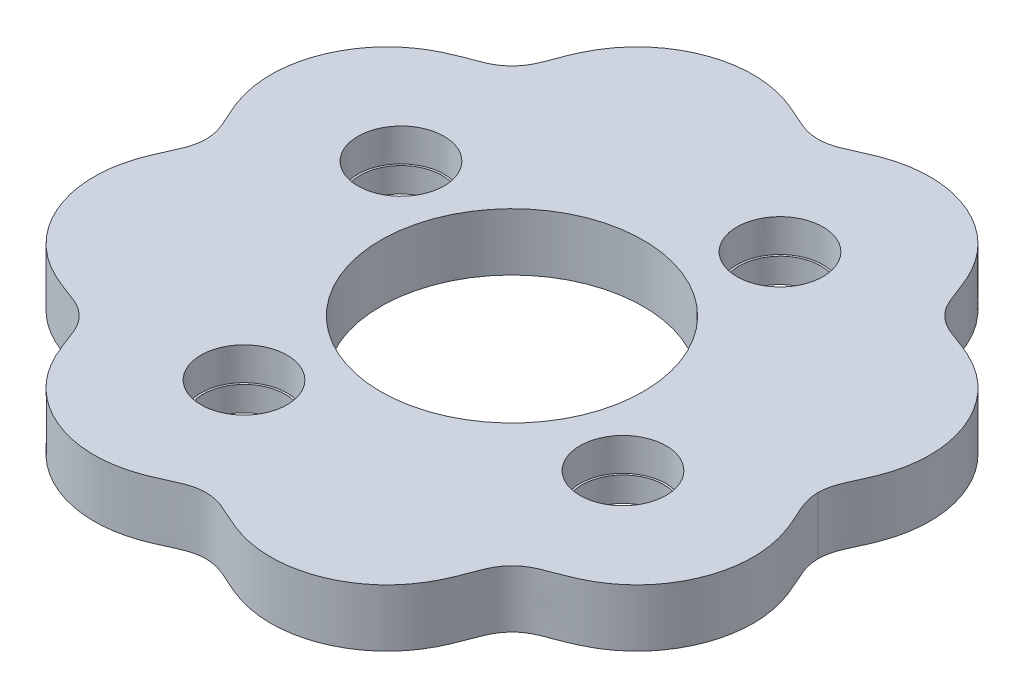
from build123d import *

# Parameters (mm, degrees)
BOSS_EXTRUDE1_DEPTH = 7
SKETCH3_R           = 16
SKETCH3_R_2         = 5.25
CUT_EXTRUDE1_DEPTH  = 7
CUT_EXTRUDE2_DEPTH  = 7
SKETCH5_R           = 5.25
SKETCH5_R_2         = 5
BOSS_EXTRUDE2_DEPTH = 3


with BuildPart() as part:
    # Sketch2 → Boss-Extrude1 (new body)
    with BuildSketch(Plane(origin=(0, 0, 0), x_dir=(1, 0, 0), z_dir=(0, 1, 0))):
        with BuildLine():
            add(Edge.make_bspline(
                [(37.500000178, 0), (37.500001348, -0.153650042), (37.516723117, -0.585734713), (37.60134551, -1.155885936), (37.799451038, -1.845132779), (38.055257689, -2.50061582), (38.284413658, -3.01884437), (38.547573645, -3.586057627), (38.834335204, -4.207231283), (39.213023964, -5.071386775), (39.642902809, -6.195484546), (40.034770345, -7.545626157), (40.309114863, -9.129071904), (40.402480997, -10.733442687), (40.292330227, -12.739242447), (39.800709206, -15.115411572), (38.875008006, -17.372282299), (37.550500891, -19.416826213), (36.201869244, -20.937061223), (34.991297456, -22.022332107), (33.664442598, -22.961820777), (32.418877976, -23.648429526), (31.307176029, -24.144813461), (30.415442254, -24.492540623), (29.760772524, -24.733252947), (29.159260868, -24.953726937), (28.615153012, -25.166050116), (27.968227921, -25.455751973), (27.242450172, -25.869161743), (26.486758972, -26.478530797), (25.788934233, -27.338578085), (25.333439826, -28.199550113), (25.02084924, -28.978917238), (24.756184284, -29.69717513), (24.520071708, -30.342148991), (24.176798097, -31.229963234), (23.685673389, -32.343953643), (23.006023391, -33.593318677), (22.074382722, -34.925670234), (20.99628636, -36.142619362), (19.483992231, -37.500137581), (17.436434568, -38.843473511), (15.165772212, -39.787003781), (12.765640508, -40.290729235), (10.727941267, -40.403684264), (9.098120231, -40.306732746), (7.490297544, -40.023060283), (6.12050869, -39.618509318), (4.980859334, -39.175936442), (3.981084292, -38.733166074), (3.107747272, -38.323212218), (2.16284156, -37.896233325), (1.102684883, -37.568652762), (-4e-09, -37.451718585), (-1.102684874, -37.568652759), (-2.162841573, -37.896233332), (-3.107747248, -38.323212203), (-3.981084328, -38.733166098), (-4.980859269, -39.175936398), (-6.120508811, -39.6185094), (-7.490297349, -40.023060149), (-9.098120503, -40.306732933), (-10.727940878, -40.403683996), (-12.765641194, -40.290729708), (-15.165770912, -39.787002885), (-17.436436591, -38.843474905), (-19.48398961, -37.500135775), (-20.996290415, -36.142622155), (-22.074374394, -34.925664496), (-23.006039129, -33.59332952), (-23.685647307, -32.343935674), (-24.176838549, -31.229991103), (-24.570729586, -30.210893235), (-24.899588849, -29.300399238), (-25.267416458, -28.324512461), (-25.788900803, -27.338555053), (-26.486780724, -26.478545782), (-27.242436428, -25.869152274), (-27.968236735, -25.455758045), (-28.615147496, -25.166046316), (-29.159264206, -24.953729236), (-29.760770668, -24.733251668), (-30.415443148, -24.492541238), (-31.307175489, -24.144813089), (-32.41887831, -23.648429756), (-33.6644424, -22.96182064), (-34.99129756, -22.022332179), (-36.201869193, -20.937061188), (-37.550500924, -19.416826235), (-38.875007981, -17.372282282), (-39.800709222, -15.115411584), (-40.292330218, -12.739242441), (-40.402481002, -10.733442691), (-40.309114859, -9.129071901), (-40.034770347, -7.545626159), (-39.642902807, -6.195484545), (-39.213023965, -5.071386776), (-38.834335204, -4.207231283), (-38.547573646, -3.586057627), (-38.284413658, -3.01884437), (-38.055257689, -2.50061582), (-37.799451038, -1.845132779), (-37.60134551, -1.155885936), (-37.516723117, -0.585734713), (-37.500001348, -0.153650042), (-37.500000178, 0)],
                knots=[0.119900748, 0.119900748, 0.119900748, 0.119900748, 0.119900748, 0.123359436, 0.129627259, 0.132815238, 0.136003217, 0.139191195, 0.142379174, 0.14689104, 0.151402906, 0.160426638, 0.169450869, 0.1784751, 0.187499512, 0.196523925, 0.214572937, 0.232831382, 0.241960244, 0.251089107, 0.260218415, 0.269347723, 0.278476117, 0.283040314, 0.287604511, 0.290890352, 0.294176194, 0.297462035, 0.300747877, 0.306837966, 0.312927068, 0.319161334, 0.325493528, 0.328659626, 0.331825723, 0.336390118, 0.340954513, 0.350083302, 0.35921236, 0.368341418, 0.377470301, 0.386599184, 0.404857643, 0.423193135, 0.432360527, 0.441527919, 0.450695565, 0.459863212, 0.469030281, 0.473613816, 0.47819735, 0.484472892, 0.490748434, 0.496943117, 0.503056883, 0.509251566, 0.515527108, 0.52180265, 0.526386184, 0.530969719, 0.540136788, 0.549304435, 0.558472081, 0.567639473, 0.576806865, 0.595142357, 0.613400816, 0.622529699, 0.631658582, 0.64078764, 0.649916698, 0.659045487, 0.663609882, 0.668174277, 0.674506472, 0.680838666, 0.687072932, 0.693162034, 0.699252123, 0.702537965, 0.705823806, 0.709109648, 0.712395489, 0.716959686, 0.721523883, 0.730652277, 0.739781585, 0.748910893, 0.758039756, 0.767168618, 0.785427063, 0.803476075, 0.812500488, 0.8215249, 0.830549131, 0.839573362, 0.848597094, 0.85310896, 0.857620826, 0.860808805, 0.863996783, 0.867184762, 0.870372741, 0.876640564, 0.880099252, 0.880099252, 0.880099252, 0.880099252, 0.880099252], degree=4))
            add(Edge.make_bspline(
                [(37.500000178, 0), (37.500001348, 0.153650042), (37.516723117, 0.585734713), (37.60134551, 1.155885936), (37.799451038, 1.845132779), (38.055257689, 2.50061582), (38.284413658, 3.018844371), (38.547573645, 3.586057627), (38.834335204, 4.207231284), (39.213023964, 5.071386775), (39.642902809, 6.195484546), (40.034770345, 7.545626157), (40.309114863, 9.129071904), (40.402480997, 10.733442688), (40.292330227, 12.739242447), (39.800709205, 15.115411572), (38.875008006, 17.3722823), (37.550500891, 19.416826213), (36.201869244, 20.937061223), (34.991297456, 22.022332107), (33.664442598, 22.961820777), (32.418877976, 23.648429526), (31.307176029, 24.144813461), (30.415442254, 24.492540623), (29.760772524, 24.733252947), (29.159260868, 24.953726937), (28.615153012, 25.166050117), (27.968227921, 25.455751974), (27.242450172, 25.869161744), (26.486758972, 26.478530797), (25.788934233, 27.338578085), (25.333439826, 28.199550113), (25.02084924, 28.978917238), (24.756184284, 29.69717513), (24.520071708, 30.342148991), (24.176798097, 31.229963234), (23.685673389, 32.343953643), (23.006023391, 33.593318677), (22.074382722, 34.925670234), (20.99628636, 36.142619362), (19.483992231, 37.500137582), (17.436434568, 38.843473511), (15.165772212, 39.787003781), (12.765640508, 40.290729235), (10.727941267, 40.403684265), (9.098120231, 40.306732746), (7.490297544, 40.023060283), (6.12050869, 39.618509318), (4.980859334, 39.175936443), (3.981084292, 38.733166074), (3.107747271, 38.323212218), (2.162841559, 37.896233325), (1.102684882, 37.568652762), (-4e-09, 37.451718586), (-1.102684874, 37.568652759), (-2.162841573, 37.896233332), (-3.107747248, 38.323212203), (-3.981084328, 38.733166098), (-4.980859269, 39.175936399), (-6.120508811, 39.6185094), (-7.490297349, 40.023060149), (-9.098120503, 40.306732933), (-10.727940878, 40.403683996), (-12.765641194, 40.290729708), (-15.165770912, 39.787002885), (-17.436436591, 38.843474905), (-19.48398961, 37.500135776), (-20.996290415, 36.142622155), (-22.074374394, 34.925664496), (-23.006039129, 33.59332952), (-23.685647307, 32.343935674), (-24.176838549, 31.229991103), (-24.570729586, 30.210893235), (-24.899588849, 29.300399238), (-25.267416458, 28.324512461), (-25.788900803, 27.338555053), (-26.486780724, 26.478545782), (-27.242436428, 25.869152274), (-27.968236735, 25.455758045), (-28.615147496, 25.166046316), (-29.159264206, 24.953729236), (-29.760770668, 24.733251668), (-30.415443148, 24.492541238), (-31.307175489, 24.144813089), (-32.418878311, 23.648429756), (-33.6644424, 22.96182064), (-34.99129756, 22.022332179), (-36.201869193, 20.937061188), (-37.550500924, 19.416826235), (-38.875007981, 17.372282282), (-39.800709222, 15.115411584), (-40.292330218, 12.739242441), (-40.402481002, 10.733442691), (-40.309114859, 9.129071901), (-40.034770347, 7.545626159), (-39.642902807, 6.195484545), (-39.213023965, 5.071386776), (-38.834335204, 4.207231283), (-38.547573646, 3.586057627), (-38.284413658, 3.01884437), (-38.055257689, 2.50061582), (-37.799451038, 1.845132779), (-37.60134551, 1.155885936), (-37.516723117, 0.585734713), (-37.500001348, 0.153650042), (-37.500000178, 0)],
                knots=[0.119900748, 0.119900748, 0.119900748, 0.119900748, 0.119900748, 0.123359436, 0.129627259, 0.132815238, 0.136003217, 0.139191195, 0.142379174, 0.14689104, 0.151402906, 0.160426638, 0.169450869, 0.1784751, 0.187499512, 0.196523925, 0.214572937, 0.232831382, 0.241960244, 0.251089107, 0.260218415, 0.269347723, 0.278476117, 0.283040314, 0.287604511, 0.290890352, 0.294176194, 0.297462035, 0.300747877, 0.306837966, 0.312927068, 0.319161334, 0.325493528, 0.328659626, 0.331825723, 0.336390118, 0.340954513, 0.350083302, 0.35921236, 0.368341418, 0.377470301, 0.386599184, 0.404857643, 0.423193135, 0.432360527, 0.441527919, 0.450695565, 0.459863212, 0.469030281, 0.473613816, 0.47819735, 0.484472892, 0.490748434, 0.496943117, 0.503056883, 0.509251566, 0.515527108, 0.52180265, 0.526386184, 0.530969719, 0.540136788, 0.549304435, 0.558472081, 0.567639473, 0.576806865, 0.595142357, 0.613400816, 0.622529699, 0.631658582, 0.64078764, 0.649916698, 0.659045487, 0.663609882, 0.668174277, 0.674506472, 0.680838666, 0.687072932, 0.693162034, 0.699252123, 0.702537965, 0.705823806, 0.709109648, 0.712395489, 0.716959686, 0.721523883, 0.730652277, 0.739781585, 0.748910893, 0.758039756, 0.767168618, 0.785427063, 0.803476075, 0.812500488, 0.8215249, 0.830549131, 0.839573362, 0.848597094, 0.85310896, 0.857620826, 0.860808805, 0.863996783, 0.867184762, 0.870372741, 0.876640564, 0.880099252, 0.880099252, 0.880099252, 0.880099252, 0.880099252], degree=4))
        make_face()
    extrude(amount=BOSS_EXTRUDE1_DEPTH)

    # Sketch3 → Cut-Extrude1 (cut)
    with BuildSketch(Plane(origin=(0, 7, 0), x_dir=(1, 0, 0), z_dir=(0, 1, 0))):
        with Locations(Location((0, 0, 0), (0, 0, 270))):
            Circle(SKETCH3_R)
        with Locations(Location((23.096990508, -9.567080508, 0), (0, 0, 270))):
            Circle(SKETCH3_R_2)
        with Locations(Location((-9.567080508, -23.096990508, 0), (0, 0, 270))):
            Circle(SKETCH3_R_2)
        with Locations(Location((-23.096990508, 9.567080508, 0), (0, 0, 270))):
            Circle(SKETCH3_R_2)
        with Locations(Location((9.567080508, 23.096990508, 0), (0, 0, 270))):
            Circle(SKETCH3_R_2)
    extrude(amount=-CUT_EXTRUDE1_DEPTH, mode=Mode.SUBTRACT)

    # Sketch4 → Cut-Extrude2 (cut)
    with BuildSketch(Plane.XZ):
        with BuildLine():
            add(Edge.make_bspline(
                [(37.500000178, 0), (37.500001348, 0.153650042), (37.516723117, 0.585734713), (37.60134551, 1.155885936), (37.799451038, 1.845132779), (38.055257689, 2.50061582), (38.284413658, 3.01884437), (38.547573645, 3.586057627), (38.834335204, 4.207231283), (39.213023964, 5.071386775), (39.642902809, 6.195484546), (40.034770345, 7.545626157), (40.309114863, 9.129071904), (40.402480997, 10.733442687), (40.292330227, 12.739242447), (39.800709206, 15.115411572), (38.875008006, 17.372282299), (37.550500891, 19.416826213), (36.201869244, 20.937061223), (34.991297456, 22.022332107), (33.664442598, 22.961820777), (32.418877976, 23.648429526), (31.307176029, 24.144813461), (30.415442254, 24.492540623), (29.760772524, 24.733252947), (29.159260868, 24.953726937), (28.615153012, 25.166050116), (27.968227921, 25.455751973), (27.242450172, 25.869161743), (26.486758972, 26.478530797), (25.788934233, 27.338578085), (25.333439826, 28.199550113), (25.02084924, 28.978917238), (24.756184284, 29.69717513), (24.520071708, 30.342148991), (24.176798097, 31.229963234), (23.685673389, 32.343953643), (23.006023391, 33.593318677), (22.074382722, 34.925670234), (20.99628636, 36.142619362), (19.483992231, 37.500137581), (17.436434568, 38.843473511), (15.165772212, 39.787003781), (12.765640508, 40.290729235), (10.727941267, 40.403684264), (9.098120231, 40.306732746), (7.490297544, 40.023060283), (6.12050869, 39.618509318), (4.980859334, 39.175936442), (3.981084292, 38.733166074), (3.107747272, 38.323212218), (2.16284156, 37.896233325), (1.102684883, 37.568652762), (-4e-09, 37.451718585), (-1.102684874, 37.568652759), (-2.162841573, 37.896233332), (-3.107747248, 38.323212203), (-3.981084328, 38.733166098), (-4.980859269, 39.175936398), (-6.120508811, 39.6185094), (-7.490297349, 40.023060149), (-9.098120503, 40.306732933), (-10.727940878, 40.403683996), (-12.765641194, 40.290729708), (-15.165770912, 39.787002885), (-17.436436591, 38.843474905), (-19.48398961, 37.500135775), (-20.996290415, 36.142622155), (-22.074374394, 34.925664496), (-23.006039129, 33.59332952), (-23.685647307, 32.343935674), (-24.176838549, 31.229991103), (-24.570729586, 30.210893235), (-24.899588849, 29.300399238), (-25.267416458, 28.324512461), (-25.788900803, 27.338555053), (-26.486780724, 26.478545782), (-27.242436428, 25.869152274), (-27.968236735, 25.455758045), (-28.615147496, 25.166046316), (-29.159264206, 24.953729236), (-29.760770668, 24.733251668), (-30.415443148, 24.492541238), (-31.307175489, 24.144813089), (-32.41887831, 23.648429756), (-33.6644424, 22.96182064), (-34.99129756, 22.022332179), (-36.201869193, 20.937061188), (-37.550500924, 19.416826235), (-38.875007981, 17.372282282), (-39.800709222, 15.115411584), (-40.292330218, 12.739242441), (-40.402481002, 10.733442691), (-40.309114859, 9.129071901), (-40.034770347, 7.545626159), (-39.642902807, 6.195484545), (-39.213023965, 5.071386776), (-38.834335204, 4.207231283), (-38.547573646, 3.586057627), (-38.284413658, 3.01884437), (-38.055257689, 2.50061582), (-37.799451038, 1.845132779), (-37.60134551, 1.155885936), (-37.516723117, 0.585734713), (-37.500001348, 0.153650042), (-37.500000178, 0)],
                knots=[0.119900748, 0.119900748, 0.119900748, 0.119900748, 0.119900748, 0.123359436, 0.129627259, 0.132815238, 0.136003217, 0.139191195, 0.142379174, 0.14689104, 0.151402906, 0.160426638, 0.169450869, 0.1784751, 0.187499512, 0.196523925, 0.214572937, 0.232831382, 0.241960244, 0.251089107, 0.260218415, 0.269347723, 0.278476117, 0.283040314, 0.287604511, 0.290890352, 0.294176194, 0.297462035, 0.300747877, 0.306837966, 0.312927068, 0.319161334, 0.325493528, 0.328659626, 0.331825723, 0.336390118, 0.340954513, 0.350083302, 0.35921236, 0.368341418, 0.377470301, 0.386599184, 0.404857643, 0.423193135, 0.432360527, 0.441527919, 0.450695565, 0.459863212, 0.469030281, 0.473613816, 0.47819735, 0.484472892, 0.490748434, 0.496943117, 0.503056883, 0.509251566, 0.515527108, 0.52180265, 0.526386184, 0.530969719, 0.540136788, 0.549304435, 0.558472081, 0.567639473, 0.576806865, 0.595142357, 0.613400816, 0.622529699, 0.631658582, 0.64078764, 0.649916698, 0.659045487, 0.663609882, 0.668174277, 0.674506472, 0.680838666, 0.687072932, 0.693162034, 0.699252123, 0.702537965, 0.705823806, 0.709109648, 0.712395489, 0.716959686, 0.721523883, 0.730652277, 0.739781585, 0.748910893, 0.758039756, 0.767168618, 0.785427063, 0.803476075, 0.812500488, 0.8215249, 0.830549131, 0.839573362, 0.848597094, 0.85310896, 0.857620826, 0.860808805, 0.863996783, 0.867184762, 0.870372741, 0.876640564, 0.880099252, 0.880099252, 0.880099252, 0.880099252, 0.880099252], degree=4))
            add(Edge.make_bspline(
                [(-37.500000178, 0), (-37.500001348, -0.153650042), (-37.516723117, -0.585734713), (-37.60134551, -1.155885936), (-37.799451038, -1.845132779), (-38.055257689, -2.50061582), (-38.284413658, -3.01884437), (-38.547573646, -3.586057627), (-38.834335204, -4.207231283), (-39.213023965, -5.071386776), (-39.642902807, -6.195484545), (-40.034770347, -7.545626159), (-40.309114859, -9.129071901), (-40.402481002, -10.733442691), (-40.292330218, -12.739242441), (-39.800709222, -15.115411584), (-38.875007981, -17.372282282), (-37.550500924, -19.416826235), (-36.201869193, -20.937061188), (-34.99129756, -22.022332179), (-33.6644424, -22.96182064), (-32.418878311, -23.648429756), (-31.307175489, -24.144813089), (-30.415443148, -24.492541238), (-29.760770668, -24.733251668), (-29.159264206, -24.953729236), (-28.615147496, -25.166046316), (-27.968236735, -25.455758045), (-27.242436428, -25.869152274), (-26.486780724, -26.478545782), (-25.788900803, -27.338555053), (-25.267416458, -28.324512461), (-24.899588849, -29.300399238), (-24.570729586, -30.210893235), (-24.176838549, -31.229991103), (-23.685647307, -32.343935674), (-23.006039129, -33.59332952), (-22.074374394, -34.925664496), (-20.996290415, -36.142622155), (-19.48398961, -37.500135776), (-17.436436591, -38.843474905), (-15.165770912, -39.787002885), (-12.765641194, -40.290729708), (-10.727940878, -40.403683996), (-9.098120503, -40.306732933), (-7.490297349, -40.023060149), (-6.120508811, -39.6185094), (-4.980859269, -39.175936399), (-3.981084328, -38.733166098), (-3.107747248, -38.323212203), (-2.162841573, -37.896233332), (-1.102684874, -37.568652759), (-4e-09, -37.451718586), (1.102684882, -37.568652762), (2.162841559, -37.896233325), (3.107747271, -38.323212218), (3.981084292, -38.733166074), (4.980859334, -39.175936443), (6.12050869, -39.618509318), (7.490297544, -40.023060283), (9.098120231, -40.306732746), (10.727941267, -40.403684265), (12.765640508, -40.290729235), (15.165772212, -39.787003781), (17.436434568, -38.843473511), (19.483992231, -37.500137582), (20.99628636, -36.142619362), (22.074382722, -34.925670234), (23.006023391, -33.593318677), (23.685673389, -32.343953643), (24.176798097, -31.229963234), (24.520071708, -30.342148991), (24.756184284, -29.69717513), (25.02084924, -28.978917238), (25.333439826, -28.199550113), (25.788934233, -27.338578085), (26.486758972, -26.478530797), (27.242450172, -25.869161744), (27.968227921, -25.455751974), (28.615153012, -25.166050117), (29.159260868, -24.953726937), (29.760772524, -24.733252947), (30.415442254, -24.492540623), (31.307176029, -24.144813461), (32.418877976, -23.648429526), (33.664442598, -22.961820777), (34.991297456, -22.022332107), (36.201869244, -20.937061223), (37.550500891, -19.416826213), (38.875008006, -17.3722823), (39.800709205, -15.115411572), (40.292330227, -12.739242447), (40.402480997, -10.733442688), (40.309114863, -9.129071904), (40.034770345, -7.545626157), (39.642902809, -6.195484546), (39.213023964, -5.071386775), (38.834335204, -4.207231284), (38.547573645, -3.586057627), (38.284413658, -3.018844371), (38.055257689, -2.50061582), (37.799451038, -1.845132779), (37.60134551, -1.155885936), (37.516723117, -0.585734713), (37.500001348, -0.153650042), (37.500000178, 0)],
                knots=[0.119900748, 0.119900748, 0.119900748, 0.119900748, 0.119900748, 0.123359436, 0.129627259, 0.132815238, 0.136003217, 0.139191195, 0.142379174, 0.14689104, 0.151402906, 0.160426638, 0.169450869, 0.1784751, 0.187499512, 0.196523925, 0.214572937, 0.232831382, 0.241960244, 0.251089107, 0.260218415, 0.269347723, 0.278476117, 0.283040314, 0.287604511, 0.290890352, 0.294176194, 0.297462035, 0.300747877, 0.306837966, 0.312927068, 0.319161334, 0.325493528, 0.331825723, 0.336390118, 0.340954513, 0.350083302, 0.35921236, 0.368341418, 0.377470301, 0.386599184, 0.404857643, 0.423193135, 0.432360527, 0.441527919, 0.450695565, 0.459863212, 0.469030281, 0.473613816, 0.47819735, 0.484472892, 0.490748434, 0.496943117, 0.503056883, 0.509251566, 0.515527108, 0.52180265, 0.526386184, 0.530969719, 0.540136788, 0.549304435, 0.558472081, 0.567639473, 0.576806865, 0.595142357, 0.613400816, 0.622529699, 0.631658582, 0.64078764, 0.649916698, 0.659045487, 0.663609882, 0.668174277, 0.671340374, 0.674506472, 0.680838666, 0.687072932, 0.693162034, 0.699252123, 0.702537965, 0.705823806, 0.709109648, 0.712395489, 0.716959686, 0.721523883, 0.730652277, 0.739781585, 0.748910893, 0.758039756, 0.767168618, 0.785427063, 0.803476075, 0.812500488, 0.8215249, 0.830549131, 0.839573362, 0.848597094, 0.85310896, 0.857620826, 0.860808805, 0.863996783, 0.867184762, 0.870372741, 0.876640564, 0.880099252, 0.880099252, 0.880099252, 0.880099252, 0.880099252], degree=4))
        make_face()
        with BuildLine():
            add(Edge.make_bspline(
                [(-37.300000178, -1.524e-06), (-37.300005335, -0.676867371), (-37.427636497, -1.325473476), (-37.853250651, -2.584965326), (-38.147131523, -3.195245044), (-38.710737195, -4.418667543), (-38.982798601, -5.033561115), (-39.450771862, -6.288224734), (-39.648035819, -6.927553077), (-39.875673706, -7.908844077), (-39.940344955, -8.239602513), (-40.046090854, -8.908827903), (-40.087286369, -9.248679407), (-40.172949866, -10.27022305), (-40.179625206, -10.947626333), (-40.096430658, -12.295492001), (-40.006581856, -12.965955902), (-39.798317767, -13.966368295), (-39.716248424, -14.299914705), (-39.529875703, -14.955124894), (-39.425421525, -15.277863119), (-39.07900274, -16.231799922), (-38.804163449, -16.848799053), (-38.166153555, -18.044644678), (-37.799492988, -18.627625556), (-36.995130035, -19.722329216), (-36.55702023, -20.236493497), (-35.609382413, -21.198851965), (-35.098848237, -21.647731332), (-34.006848553, -22.473314445), (-33.436641819, -22.841333302), (-32.252551038, -23.49658613), (-31.638105387, -23.782781365), (-30.693579545, -24.169797582), (-30.374923098, -24.29196642), (-29.735334328, -24.530156066), (-29.414121244, -24.64587707), (-28.776119551, -24.887840957), (-28.459558035, -25.014623888), (-27.841899581, -25.30496618), (-27.538474652, -25.470402701), (-26.968530323, -25.84818003), (-26.70266287, -26.059307537), (-26.212204012, -26.529609939), (-25.985689891, -26.791762949), (-25.586463853, -27.347680771), (-25.41329678, -27.640928729), (-25.106118272, -28.250061479), (-24.972145407, -28.566214123), (-24.721951409, -29.207052359), (-24.604673392, -29.531396076), (-24.365978823, -30.178006246), (-24.244860769, -30.500422525), (-23.861965565, -31.457863081), (-23.579994139, -32.082751199), (-22.93073246, -33.289703159), (-22.564564445, -33.872330289), (-21.944749407, -34.710853127), (-21.725410999, -34.985571353), (-21.270313026, -35.513530833), (-21.034058454, -35.767647044), (-20.299828428, -36.501142055), (-19.77651621, -36.951814008), (-18.662658422, -37.776981752), (-18.067184766, -38.153631121), (-16.84205779, -38.808251323), (-16.210381542, -39.088693428), (-15.234619198, -39.440087375), (-14.904636476, -39.545623277), (-14.235030876, -39.733055651), (-13.893995034, -39.815213549), (-12.183094407, -40.161008791), (-10.804309777, -40.234150035), (-9.068024089, -40.066663686), (-8.719971551, -40.019815553), (-8.033988167, -39.901414802), (-7.694604804, -39.829735338), (-6.686761662, -39.579051281), (-6.02890771, -39.363367369), (-4.734913886, -38.856903314), (-4.09967909, -38.563862442), (-2.831226885, -37.978648162), (-2.195461735, -37.68983752), (-1.177345947, -37.415650241), (-0.830881373, -37.351821484), (-0.138817065, -37.29091559), (0.20907518, -37.292911809), (0.908697102, -37.363847996), (1.254123511, -37.432795894), (1.923534855, -37.620991628), (2.250175655, -37.740536869), (2.894567623, -38.007677129), (3.212569296, -38.154445485), (3.848679122, -38.448235746), (4.166662192, -38.595380732), (5.126011798, -39.018034516), (5.77299927, -39.273995175), (7.093462946, -39.693795626), (7.766556663, -39.858965602), (8.79794485, -40.031088074), (9.145338463, -40.075950894), (9.84763557, -40.139559133), (10.204439892, -40.158296893), (11.981061205, -40.183352107), (13.374101934, -39.99116426), (15.0807472, -39.4906324), (15.418995639, -39.377488677), (16.081101817, -39.128399482), (16.406210156, -38.992100462), (17.363980082, -38.548492104), (17.97919541, -38.206686663), (18.866236672, -37.623228073), (19.157096225, -37.415961043), (19.7199732, -36.981810571), (19.991631279, -36.755377595), (20.777834873, -36.048551371), (21.26373655, -35.540752153), (21.934837883, -34.723797907), (22.148877277, -34.442236285), (22.557321054, -33.860326574), (22.751308058, -33.560329192), (23.296633068, -32.645197526), (23.613079431, -32.01037547), (24.035024821, -31.030456758), (24.167085908, -30.699362692), (24.42071489, -30.03357086), (24.542165455, -29.698502186), (24.789943229, -29.030340214), (24.916288451, -28.697254212), (25.203031469, -28.04487583), (25.365328746, -27.723501519), (25.738863592, -27.118626541), (25.949588891, -26.83484909), (26.425345949, -26.30959178), (26.693427061, -26.066305249), (27.262376931, -25.640526196), (27.56458752, -25.45587752), (28.196201984, -25.129880607), (28.525768024, -24.988616885), (29.195057198, -24.725991917), (29.534624796, -24.603555748), (30.211020774, -24.35374453), (30.54805671, -24.22674371), (31.547163494, -23.824103094), (32.196759504, -23.525970845), (33.44512828, -22.83807073), (34.04463883, -22.449633109), (34.902881218, -21.793010366), (35.18215621, -21.561865079), (35.726440643, -21.073853349), (35.992909512, -20.815365155), (36.754934237, -20.015059637), (37.215569576, -19.447621742), (38.045919188, -18.247692555), (38.41581225, -17.614905719), (39.060809726, -16.283216984), (39.327825486, -15.601135481), (39.755290796, -14.205785793), (39.915743077, -13.492518407), (40.073287437, -12.398288082), (40.111713427, -12.029358579), (40.159120983, -11.296377239), (40.168380307, -10.930685523), (40.153413888, -9.835974665), (40.086539323, -9.109314524), (39.899940664, -8.024097027), (39.822944519, -7.661850311), (39.641972096, -6.946076066), (39.53821078, -6.592991809), (39.19106012, -5.546715434), (38.9097543, -4.867241305), (38.454863731, -3.859944684), (38.297872988, -3.526119045), (37.992404669, -2.855385887), (37.844569648, -2.518245277), (37.590630842, -1.828852716), (37.484865024, -1.476478384), (37.339064604, -0.747927725), (37.300003029, -0.374141758), (37.300000178, -1.524e-06)],
                knots=[0, 0, 0, 0, 0.015625, 0.015625, 0.03125, 0.03125, 0.046875, 0.046875, 0.0625, 0.0625, 0.0703125, 0.0703125, 0.078125, 0.078125, 0.09375, 0.09375, 0.109375, 0.109375, 0.1171875, 0.1171875, 0.125, 0.125, 0.140625, 0.140625, 0.15625, 0.15625, 0.171875, 0.171875, 0.1875, 0.1875, 0.203125, 0.203125, 0.21875, 0.21875, 0.2265625, 0.2265625, 0.234375, 0.234375, 0.2421875, 0.2421875, 0.25, 0.25, 0.2578125, 0.2578125, 0.265625, 0.265625, 0.2734375, 0.2734375, 0.28125, 0.28125, 0.2890625, 0.2890625, 0.296875, 0.296875, 0.3125, 0.3125, 0.328125, 0.328125, 0.3359375, 0.3359375, 0.34375, 0.34375, 0.359375, 0.359375, 0.375, 0.375, 0.390625, 0.390625, 0.3984375, 0.3984375, 0.40625, 0.40625, 0.4375, 0.4375, 0.4453125, 0.4453125, 0.453125, 0.453125, 0.46875, 0.46875, 0.484375, 0.484375, 0.5, 0.5, 0.5078125, 0.5078125, 0.515625, 0.515625, 0.5234375, 0.5234375, 0.53125, 0.53125, 0.5390625, 0.5390625, 0.546875, 0.546875, 0.5625, 0.5625, 0.578125, 0.578125, 0.5859375, 0.5859375, 0.59375, 0.59375, 0.625, 0.625, 0.6328125, 0.6328125, 0.640625, 0.640625, 0.65625, 0.65625, 0.6640625, 0.6640625, 0.671875, 0.671875, 0.6875, 0.6875, 0.6953125, 0.6953125, 0.703125, 0.703125, 0.71875, 0.71875, 0.7265625, 0.7265625, 0.734375, 0.734375, 0.7421875, 0.7421875, 0.75, 0.75, 0.7578125, 0.7578125, 0.765625, 0.765625, 0.7734375, 0.7734375, 0.78125, 0.78125, 0.7890625, 0.7890625, 0.796875, 0.796875, 0.8125, 0.8125, 0.828125, 0.828125, 0.8359375, 0.8359375, 0.84375, 0.84375, 0.859375, 0.859375, 0.875, 0.875, 0.890625, 0.890625, 0.90625, 0.90625, 0.9140625, 0.9140625, 0.921875, 0.921875, 0.9375, 0.9375, 0.9453125, 0.9453125, 0.953125, 0.953125, 0.96875, 0.96875, 0.9765625, 0.9765625, 0.984375, 0.984375, 0.9921875, 0.9921875, 1, 1, 1, 1], degree=3))
            add(Edge.make_bspline(
                [(37.300000178, -1.524e-06), (37.300005208, 0.660144226), (37.421411779, 1.295517379), (37.831734078, 2.532082599), (38.116935876, 3.130913102), (38.66996567, 4.329106329), (38.939096345, 4.930571557), (39.405964802, 6.156402501), (39.605047777, 6.780336723), (39.916633728, 8.055977178), (40.029822796, 8.707463335), (40.129263615, 9.707256218), (40.150476293, 10.043512099), (40.168603216, 10.710754532), (40.16569842, 11.043295862), (40.121853762, 12.037750073), (40.04596153, 12.696509229), (39.800930827, 14.005614003), (39.629929243, 14.660025043), (39.203319809, 15.922840902), (38.947607438, 16.534995728), (38.352443795, 17.721287864), (38.01164261, 18.297386991), (36.865619793, 19.953006208), (35.965077358, 20.925749976), (34.668200294, 21.977408574), (34.399137664, 22.180045191), (33.849124311, 22.564175613), (33.568194294, 22.745768199), (32.708435952, 23.26054556), (32.112158136, 23.562879166), (30.883355545, 24.103460776), (30.253463108, 24.33873727), (28.992284812, 24.802673436), (28.359269177, 25.033693876), (27.173041908, 25.672514094), (26.640421314, 26.071830768), (25.732243211, 27.075117404), (25.3881266, 27.646349548), (24.970450113, 28.565526018), (24.847078992, 28.880994442), (24.608670909, 29.516260023), (24.493248755, 29.835986238), (24.136201537, 30.789197307), (23.882826599, 31.416178136), (23.0112342, 33.235418868), (22.282526036, 34.366517759), (21.14183152, 35.65318275), (20.900908683, 35.905544246), (20.402861765, 36.389571629), (20.146235185, 36.621002802), (19.354227833, 37.284497662), (18.796838061, 37.685927789), (17.917194752, 38.227445206), (17.616690295, 38.397804286), (17.000801173, 38.717811199), (16.685302872, 38.867360076), (15.731897553, 39.277610568), (15.082085717, 39.502910242), (13.754543594, 39.858798155), (13.076303966, 39.989464784), (11.692472346, 40.150698781), (11.003326073, 40.179384795), (9.630398499, 40.136159356), (8.946624716, 40.064106935), (7.925054091, 39.879336655), (7.584068392, 39.804584904), (6.911102375, 39.631582084), (6.578787823, 39.533352223), (5.593179411, 39.206769583), (4.951763876, 38.944995717), (4.001222146, 38.519748784), (3.686215525, 38.37274594), (3.054939486, 38.082334811), (2.738671787, 37.939003624), (1.774376643, 37.555125527), (1.108416265, 37.365702832), (-0.313242705, 37.26305357), (-1.009819495, 37.353721127), (-2.373134662, 37.759482708), (-3.020435969, 38.065714366), (-4.31922425, 38.665586321), (-4.970996576, 38.958368217), (-6.303290418, 39.457448435), (-6.983156607, 39.665718112), (-8.028742238, 39.900551902), (-8.38150253, 39.966099849), (-9.095953619, 40.070330911), (-9.459164574, 40.109032745), (-10.542292685, 40.181785054), (-11.260648975, 40.173939549), (-12.690162629, 40.049472575), (-13.402303785, 39.93264955), (-14.815140156, 39.587636547), (-15.49961688, 39.363583018), (-16.826571564, 38.816808356), (-17.469046393, 38.49407987), (-18.400199275, 37.933495503), (-18.705278844, 37.733539312), (-19.293957386, 37.314680679), (-19.578928892, 37.095003085), (-20.406107655, 36.405627556), (-20.920721522, 35.905742621), (-21.636047699, 35.094001047), (-21.865738476, 34.812071146), (-22.30216479, 34.231468298), (-22.507864629, 33.934330063), (-23.089081297, 33.023310305), (-23.427950481, 32.389405873), (-24.026693363, 31.078436817), (-24.284665302, 30.399987851), (-24.785829721, 29.038501872), (-25.029748887, 28.354949713), (-25.555483159, 27.397017304), (-25.757179306, 27.090563947), (-26.210844694, 26.529370711), (-26.463914838, 26.271703557), (-27.024732982, 25.804153386), (-27.327595986, 25.59913821), (-27.958226263, 25.242998486), (-28.288028419, 25.090485933), (-28.962903163, 24.812754276), (-29.306820586, 24.686962968), (-29.994054984, 24.434168853), (-30.337434391, 24.307292012), (-31.357424955, 23.906187), (-32.023447973, 23.610595593), (-33.307440523, 22.922457321), (-33.926138193, 22.531379588), (-34.81427105, 21.864230931), (-35.10265734, 21.629071247), (-35.654941854, 21.141050975), (-35.920235243, 20.887187618), (-36.684231882, 20.096640102), (-37.151243071, 19.531172398), (-37.787653083, 18.624747418), (-37.989747764, 18.311551138), (-38.36606589, 17.675179304), (-38.540902679, 17.351335772), (-39.026418472, 16.363245214), (-39.298355219, 15.682545383), (-39.737624204, 14.276722964), (-39.904584783, 13.547861194), (-40.120046777, 12.093980332), (-40.170830834, 11.363377776), (-40.160755091, 10.261927286), (-40.14295873, 9.893848663), (-40.077625461, 9.155778871), (-40.030026871, 8.78681187), (-39.845507073, 7.696104416), (-39.665898802, 6.984547803), (-39.207134795, 5.588841869), (-38.92583868, 4.904518844), (-38.469054097, 3.890595764), (-38.311220852, 3.55473841), (-38.003352456, 2.88006077), (-37.853918969, 2.54101188), (-37.596472589, 1.847176107), (-37.488836022, 1.492246237), (-37.340112082, 0.757100749), (-37.300003062, 0.378477949), (-37.300000178, -1.524e-06)],
                knots=[0, 0, 0, 0, 0.015625, 0.015625, 0.03125, 0.03125, 0.046875, 0.046875, 0.0625, 0.0625, 0.078125, 0.078125, 0.0859375, 0.0859375, 0.09375, 0.09375, 0.109375, 0.109375, 0.125, 0.125, 0.140625, 0.140625, 0.15625, 0.15625, 0.1875, 0.1875, 0.1953125, 0.1953125, 0.203125, 0.203125, 0.21875, 0.21875, 0.234375, 0.234375, 0.25, 0.25, 0.265625, 0.265625, 0.28125, 0.28125, 0.2890625, 0.2890625, 0.296875, 0.296875, 0.3125, 0.3125, 0.34375, 0.34375, 0.3515625, 0.3515625, 0.359375, 0.359375, 0.375, 0.375, 0.3828125, 0.3828125, 0.390625, 0.390625, 0.40625, 0.40625, 0.421875, 0.421875, 0.4375, 0.4375, 0.453125, 0.453125, 0.4609375, 0.4609375, 0.46875, 0.46875, 0.484375, 0.484375, 0.4921875, 0.4921875, 0.5, 0.5, 0.515625, 0.515625, 0.53125, 0.53125, 0.546875, 0.546875, 0.5625, 0.5625, 0.578125, 0.578125, 0.5859375, 0.5859375, 0.59375, 0.59375, 0.609375, 0.609375, 0.625, 0.625, 0.640625, 0.640625, 0.65625, 0.65625, 0.6640625, 0.6640625, 0.671875, 0.671875, 0.6875, 0.6875, 0.6953125, 0.6953125, 0.703125, 0.703125, 0.71875, 0.71875, 0.734375, 0.734375, 0.75, 0.75, 0.7578125, 0.7578125, 0.765625, 0.765625, 0.7734375, 0.7734375, 0.78125, 0.78125, 0.7890625, 0.7890625, 0.796875, 0.796875, 0.8125, 0.8125, 0.828125, 0.828125, 0.8359375, 0.8359375, 0.84375, 0.84375, 0.859375, 0.859375, 0.8671875, 0.8671875, 0.875, 0.875, 0.890625, 0.890625, 0.90625, 0.90625, 0.921875, 0.921875, 0.9296875, 0.9296875, 0.9375, 0.9375, 0.953125, 0.953125, 0.96875, 0.96875, 0.9765625, 0.9765625, 0.984375, 0.984375, 0.9921875, 0.9921875, 1, 1, 1, 1], degree=3))
        make_face(mode=Mode.SUBTRACT)
    extrude(amount=-CUT_EXTRUDE2_DEPTH, mode=Mode.SUBTRACT)

    # Sketch5 → Boss-Extrude2 (add)
    with BuildSketch(Plane.XZ):
        with Locations(Location((-9.567080508, 23.096990508, 0), (0, 0, 90))):
            Circle(SKETCH5_R)
        with Locations(Location((-9.567080508, 23.096990508, 0), (0, 0, 270))):
            Circle(SKETCH5_R_2, mode=Mode.SUBTRACT)
        with Locations(Location((23.096990508, 9.567080508, 0), (0, 0, 90))):
            Circle(SKETCH5_R)
        with Locations(Location((23.096990508, 9.567080508, 0), (0, 0, 270))):
            Circle(SKETCH5_R_2, mode=Mode.SUBTRACT)
        with Locations(Location((-23.096990508, -9.567080508, 0), (0, 0, 90))):
            Circle(SKETCH5_R)
        with Locations(Location((-23.096990508, -9.567080508, 0), (0, 0, 270))):
            Circle(SKETCH5_R_2, mode=Mode.SUBTRACT)
        with Locations(Location((9.567080508, -23.096990508, 0), (0, 0, 90))):
            Circle(SKETCH5_R)
        with Locations(Location((9.567080508, -23.096990508, 0), (0, 0, 270))):
            Circle(SKETCH5_R_2, mode=Mode.SUBTRACT)
    extrude(amount=-BOSS_EXTRUDE2_DEPTH)


solid = part.part
